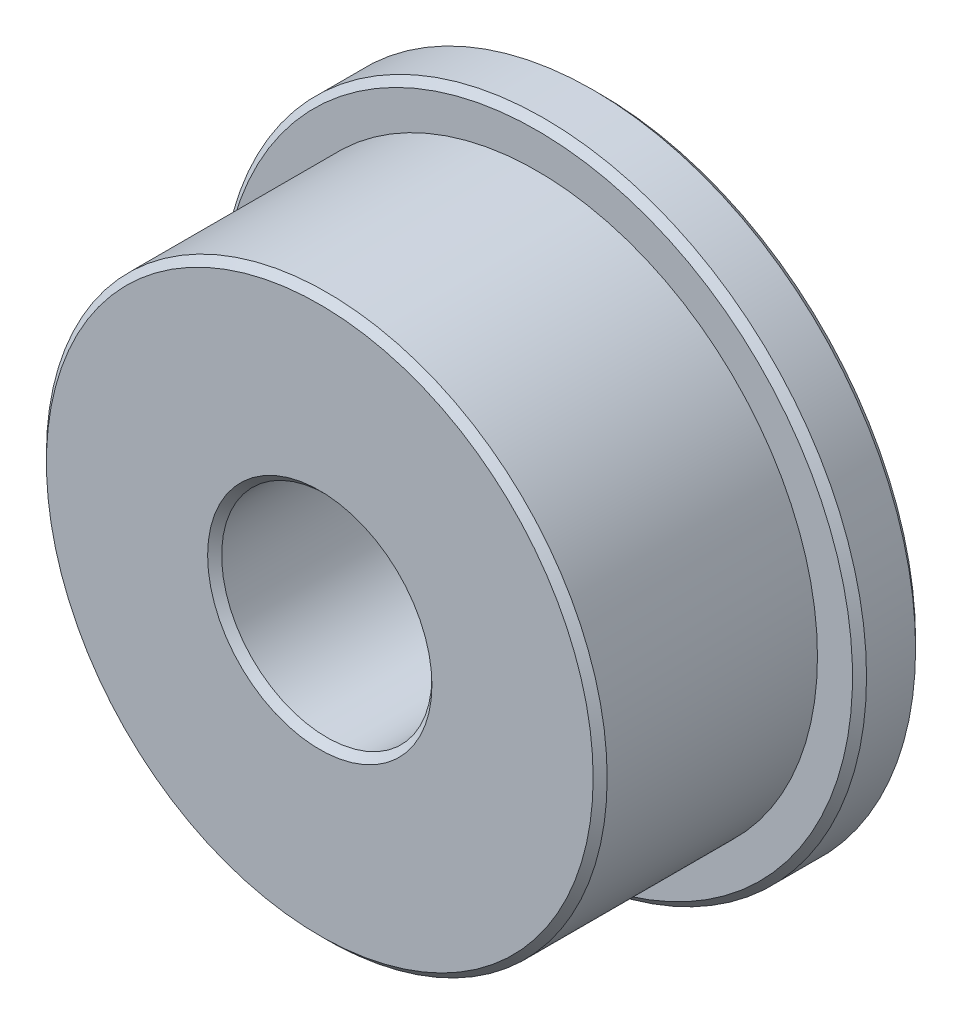
from build123d import *

# Parameters (mm, degrees)
SKETCH_1_R      = 4
SKETCH_1_R_2    = 1.5
EXTRUDE_1_DEPTH = 2
SKETCH_2_R      = 4.6
SKETCH_2_R_2    = 4
EXTRUDE_2_DEPTH = 0.9
CHAMFER_1_SIZE  = 0.1


with BuildPart() as part:
    # 草图1 → 凸台-拉伸1 (new body, symmetric)
    with BuildSketch(Plane.XY):
        Circle(SKETCH_1_R)
        Circle(SKETCH_1_R_2, mode=Mode.SUBTRACT)
    extrude(amount=EXTRUDE_1_DEPTH, both=True)

    # 草图2 → 凸台-拉伸2 (add)
    with BuildSketch(Plane(origin=(0, 0, -2), x_dir=(-1, 0, 0), z_dir=(0, 0, -1))):
        Circle(SKETCH_2_R)
        Circle(SKETCH_2_R_2, mode=Mode.SUBTRACT)
    extrude(amount=-EXTRUDE_2_DEPTH)

    # 倒角1
    chamfer_1_edges = [part.edges().sort_by_distance(p)[0] for p in [
        (4.6, 0, -1.1),
        (4.6, 0, -2),
        (-4, 0, 2),
        (-1.5, 0, -2),
        (-1.5, 0, 2),
    ]]
    chamfer(chamfer_1_edges, length=CHAMFER_1_SIZE)


solid = part.part
